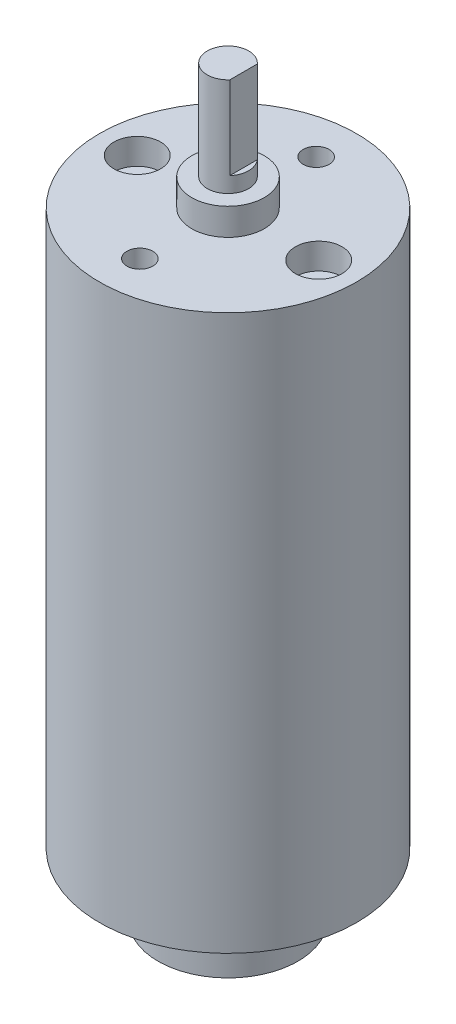
from build123d import *

# Parameters (mm, degrees)
CROQUIS3_R            = 2.25
CROQUIS3_R_2          = 1.25
CORTAR_EXTRUIR1_DEPTH = 2.5
CORTAR_EXTRUIR2_DEPTH = 8


with BuildPart() as part:
    # Croquis2 → Revolución1 (revolve)
    with BuildSketch(Plane.XY):
        Polygon((0, 0), (1, 0), (1, 2.05), (6.75, 2.05), (6.75, 6.05), (1, 6.05), (1, 8.1), (12.4, 8.1), (12.4, 61.6), (3.5, 61.6), (3.5, 64.2), (2, 64.2), (2, 73.7), (0, 73.7), align=None)
    revolve(axis=Axis((0, 73.7, 0), (0, -1, 0)))

    # Croquis3 → Cortar-Extruir1 (cut)
    with BuildSketch(Plane(origin=(0, 61.6, 0), x_dir=(1, 0, 0), z_dir=(0, 1, 0))):
        with Locations((8.75, 0)):
            Circle(CROQUIS3_R)
        with Locations((-8.75, 0)):
            Circle(CROQUIS3_R)
        with Locations((0, 8.5)):
            Circle(CROQUIS3_R_2)
        with Locations((0, -8.5)):
            Circle(CROQUIS3_R_2)
    extrude(amount=-CORTAR_EXTRUIR1_DEPTH, mode=Mode.SUBTRACT)

    # Croquis4 → Cortar-Extruir2 (cut)
    with BuildSketch(Plane(origin=(0, 73.7, 0), x_dir=(1, 0, 0), z_dir=(0, 1, 0))):
        Polygon((1.5, 50.388324137), (1.5, 1.322875656), (1.5, -1.322875656), (1.5, -50.388324137), (99.630896962, -50.388324137), (99.630896962, 50.388324137), align=None)
    extrude(amount=-CORTAR_EXTRUIR2_DEPTH, mode=Mode.SUBTRACT)


solid = part.part
